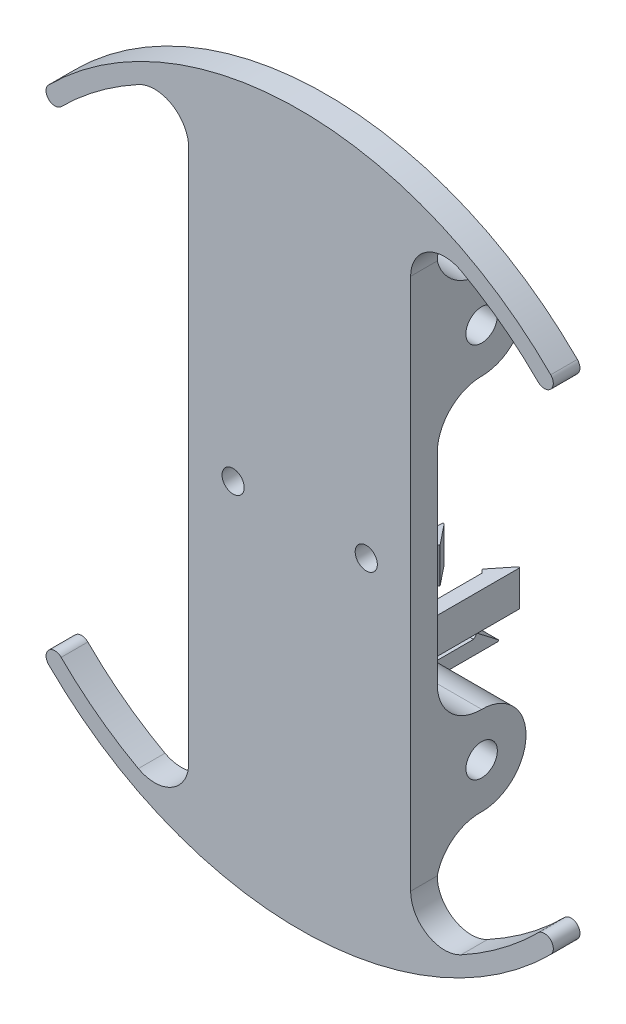
from build123d import *

# Parameters (mm, degrees)
BOSS_EXTRUDE2_DEPTH                 = 3.81
BOSS_EXTRUDE4_DEPTH                 = 31.75
F_8_CLEARANCE_HOLE1_D               = 4.4958
PARACHUTE_SHROUD_HOLE_LOW_PROFILE_D = 3.175
MONOFILAMENT_HOLE_LOW_PROFILE_D     = 3.175
BOSS_EXTRUDE7_REACH                 = 67.656
SKETCH21_W                          = 2.032
SKETCH21_H                          = 5.08
SKETCH21_W_2                        = 5.08
SKETCH21_H_2                        = 2.032
SKETCH22_W                          = 11.064
SKETCH22_H                          = 10.632
BOSS_EXTRUDE8_DEPTH                 = 7.894195
BOSS_EXTRUDE9_REACH                 = 87.468
BOSS_EXTRUDE10_DEPTH                = 5.08
FILLET3_R                           = 0.127


with BuildPart() as part:
    # Sketch3 → Boss-Extrude2 (new body)
    with BuildSketch(Plane.XY):
        with BuildLine():
            Line((-15.875, -38.1), (-15.875, 38.1))
            ThreePointArc((-15.875, 38.1), (-18.260491841, 42.291797068), (-23.082694008, 42.38179842))
            ThreePointArc((-23.082694008, 42.38179842), (-28.900226452, 38.649767283), (-34.12497326, 34.12497326))
            ThreePointArc((-34.12497326, 34.12497326), (-35.921024484, 34.12497326), (-35.921024484, 35.921024484))
            ThreePointArc((-35.921024484, 35.921024484), (0, 50.8), (35.921024484, 35.921024484))
            ThreePointArc((35.921024484, 35.921024484), (35.921024484, 34.12497326), (34.12497326, 34.12497326))
            ThreePointArc((34.12497326, 34.12497326), (28.900226452, 38.649767283), (23.082694008, 42.38179842))
            ThreePointArc((23.082694008, 42.38179842), (18.260491841, 42.291797068), (15.875, 38.1))
            Line((15.875, 38.1), (15.875, -38.1))
            ThreePointArc((15.875, -38.1), (18.260491841, -42.291797068), (23.082694008, -42.38179842))
            ThreePointArc((23.082694008, -42.38179842), (28.900226452, -38.649767283), (34.12497326, -34.12497326))
            ThreePointArc((34.12497326, -34.12497326), (35.921024484, -34.12497326), (35.921024484, -35.921024484))
            ThreePointArc((35.921024484, -35.921024484), (0, -50.8), (-35.921024484, -35.921024484))
            ThreePointArc((-35.921024484, -35.921024484), (-35.921024484, -34.12497326), (-34.12497326, -34.12497326))
            ThreePointArc((-34.12497326, -34.12497326), (-28.900226452, -38.649767283), (-23.082694008, -42.38179842))
            ThreePointArc((-23.082694008, -42.38179842), (-18.260491841, -42.291797068), (-15.875, -38.1))
        make_face()
    extrude(amount=BOSS_EXTRUDE2_DEPTH)

    # Sketch5 → Boss-Extrude4 (add)
    with BuildSketch(Plane(origin=(15.875, 0, 0), x_dir=(0, 0, -1), z_dir=(1, 0, 0))):
        with BuildLine():
            Line((0, 38.1), (0, 26.99385))
            Line((0, 26.99385), (0, 14.29385))
            ThreePointArc((0, 14.29385), (1.86498297, 18.77886703), (6.35, 20.64385))
            ThreePointArc((6.35, 20.64385), (12.699998494, 26.998224058), (6.341251887, 33.343843974))
            ThreePointArc((6.341251887, 33.343843974), (2.338844583, 34.612930799), (0, 38.1))
        make_face()
        with BuildLine():
            ThreePointArc((6.261703048, -20.644463916), (1.864650947, -18.840779739), (0, -14.469233029))
            Line((0, -14.469233029), (0, -26.99385))
            Line((0, -26.99385), (0, -38.1))
            ThreePointArc((0, -38.1), (2.217611083, -34.670801888), (6.077775616, -33.338012189))
            ThreePointArc((6.077775616, -33.338012189), (6.213919542, -33.33945129), (6.35, -33.34385))
            ThreePointArc((6.35, -33.34385), (12.7, -26.99385), (6.35, -20.64385))
            ThreePointArc((6.35, -20.64385), (6.305852606, -20.644312569), (6.261703048, -20.644463916))
        make_face()
    extrude(amount=-BOSS_EXTRUDE4_DEPTH)

    # 8 Clearance Hole1 (through all)
    with Locations(Plane(origin=(15.875, 0, 0), x_dir=(0, 0, -1), z_dir=(1, 0, 0))):
        with Locations((6.35, 26.99385), (6.35, -26.893399733)):
            Hole(F_8_CLEARANCE_HOLE1_D / 2)

    # Parachute shroud hole _low profile (through all)
    with Locations(Plane.XY.offset(3.81)):
        with Locations((-9.525, 0)):
            Hole(PARACHUTE_SHROUD_HOLE_LOW_PROFILE_D / 2)

    # Monofilament hole _low profile (through all)
    with Locations(Plane.XY.offset(3.81)):
        with Locations((9.525, 0)):
            Hole(MONOFILAMENT_HOLE_LOW_PROFILE_D / 2)



with BuildPart() as body_2:
    # Boss-Extrude7: up to this plane
    boss_extrude7_end = Plane(origin=(-1.6499976, -20.290855187, -25.429913438), z_dir=(0, 0.01745240643728808, 0.9998476951563912))
    # Sketch21 → Boss-Extrude7 (new, up to the surface)
    with BuildSketch(Plane.XY.offset(-16.509739), mode=Mode.PRIVATE) as boss_extrude7_sk1:
        with BuildLine():
            Line((-2.625, -22.293950072), (-0.593, -22.293950072))
            Line((-0.593, -22.293950072), (-0.593, -27.373950072))
            Line((-0.593, -27.373950072), (-2.625, -27.373950072))
            Line((-2.625, -27.373950072), (-2.625, -25.293950072))
            Line((-2.625, -25.293950072), (-2.575, -25.293950072))
            ThreePointArc((-2.575, -25.293950072), (-2.433578644, -25.235371429), (-2.375, -25.093950072))
            Line((-2.375, -25.093950072), (-2.375, -24.893950072))
            Line((-2.375, -24.893950072), (-2.625, -24.893950072))
            Line((-2.625, -24.893950072), (-2.625, -22.293950072))
        make_face()
    boss_extrude7_tool1 = split(extrude(boss_extrude7_sk1.sketch, amount=-BOSS_EXTRUDE7_REACH, mode=Mode.PRIVATE), bisect_by=boss_extrude7_end, keep=Keep.BOTH, mode=Mode.PRIVATE)
    add(boss_extrude7_tool1.solids().sort_by_distance((-1.600971, -24.831757, -16.509739))[0])
    # Sketch21 → Boss-Extrude7 (new, up to the surface)
    with BuildSketch(Plane.XY.offset(-16.509739), mode=Mode.PRIVATE) as boss_extrude7_sk2:
        with Locations((-10.641, -24.833950072)):
            Rectangle(SKETCH21_W, SKETCH21_H)
    boss_extrude7_tool2 = split(extrude(boss_extrude7_sk2.sketch, amount=-BOSS_EXTRUDE7_REACH, mode=Mode.PRIVATE), bisect_by=boss_extrude7_end, keep=Keep.BOTH, mode=Mode.PRIVATE)
    add(boss_extrude7_tool2.solids().sort_by_distance((-10.641, -24.83395, -16.509739))[0])
    # Sketch21 → Boss-Extrude7 (new, up to the surface)
    with BuildSketch(Plane.XY.offset(-16.509739), mode=Mode.PRIVATE) as boss_extrude7_sk3:
        with Locations((-6.165, -31.909950072)):
            Rectangle(SKETCH21_W_2, SKETCH21_H_2)
    boss_extrude7_tool3 = split(extrude(boss_extrude7_sk3.sketch, amount=-BOSS_EXTRUDE7_REACH, mode=Mode.PRIVATE), bisect_by=boss_extrude7_end, keep=Keep.BOTH, mode=Mode.PRIVATE)
    add(boss_extrude7_tool3.solids().sort_by_distance((-6.165, -31.90995, -16.509739))[0])


with BuildPart() as part_1:
    add(part.part)

    add(body_2.part)  # Boss-Extrude8 merges body 2
    # Sketch22 → Boss-Extrude8 (add)
    with BuildSketch(Plane.XY.offset(-16.509739)):
        with Locations((-6.125, -27.609950072)):
            Rectangle(SKETCH22_W, SKETCH22_H)
    extrude(amount=BOSS_EXTRUDE8_DEPTH)

    # Boss-Extrude9: up to this face of the body (flat: up to its plane)
    boss_extrude9_end = Plane(part_1.part.faces().sort_by_distance((-1.609, -27.373950072, -20.908008278))[0])
    # Sketch23 → Boss-Extrude9 (add, up to the picked face)
    with BuildSketch(Plane(origin=(0, -22.293950072, 0), x_dir=(1, 0, 0), z_dir=(0, 1, 0)), mode=Mode.PRIVATE) as boss_extrude9_sk1:
        Polygon((-11.657, 25.394949287), (-11.657, 28.569949287), (-9.117, 25.394949287), (-9.625, 24.886949287), (-11.657, 24.886949287), align=None)
    boss_extrude9_tool1 = split(extrude(boss_extrude9_sk1.sketch, amount=-BOSS_EXTRUDE9_REACH, mode=Mode.PRIVATE), bisect_by=boss_extrude9_end, keep=Keep.BOTH, mode=Mode.PRIVATE)
    # Sketch23 → Boss-Extrude9 (add, up to the picked face)
    with BuildSketch(Plane(origin=(0, -22.293950072, 0), x_dir=(1, 0, 0), z_dir=(0, 1, 0)), mode=Mode.PRIVATE) as boss_extrude9_sk2:
        Polygon((-0.593, 25.394949287), (-0.593, 28.569949287), (-3.133, 25.394949287), (-2.625, 24.886949287), (-0.593, 24.886949287), align=None)
    boss_extrude9_tool2 = split(extrude(boss_extrude9_sk2.sketch, amount=-BOSS_EXTRUDE9_REACH, mode=Mode.PRIVATE), bisect_by=boss_extrude9_end, keep=Keep.BOTH, mode=Mode.PRIVATE)
    add(boss_extrude9_tool1.solids().sort_by(Axis((-10.743021, -22.29395, -26.161945), (0, -1, 0)))[0])
    add(boss_extrude9_tool2.solids().sort_by(Axis((-1.506979, -22.29395, -26.161945), (0, -1, 0)))[0])

    # Sketch25 → Boss-Extrude10 (add)
    with BuildSketch(Plane(origin=(-3.625, 0, 0), x_dir=(0, 0, -1), z_dir=(1, 0, 0))):
        Polygon((25.209367036, -32.925950072), (28.511367036, -32.925950072), (25.209367036, -30.385950072), (24.701367036, -30.893950072), (24.701367036, -32.925950072), align=None)
    extrude(amount=-BOSS_EXTRUDE10_DEPTH)

    # Fillet3
    fillet3_edges = [part_1.edges().sort_by_distance(p)[0] for p in [
        (-9.117, -24.833950072, -25.394949287),
        (-11.657, -24.833950072, -28.569949287),
        (-0.593, -24.833950072, -28.569949287),
        (-3.133, -24.833950072, -25.394949287),
        (-6.165, -32.925950072, -28.511367036),
        (-6.165, -30.385950072, -25.209367036),
    ]]
    fillet(fillet3_edges, radius=FILLET3_R)


solid = part_1.part
